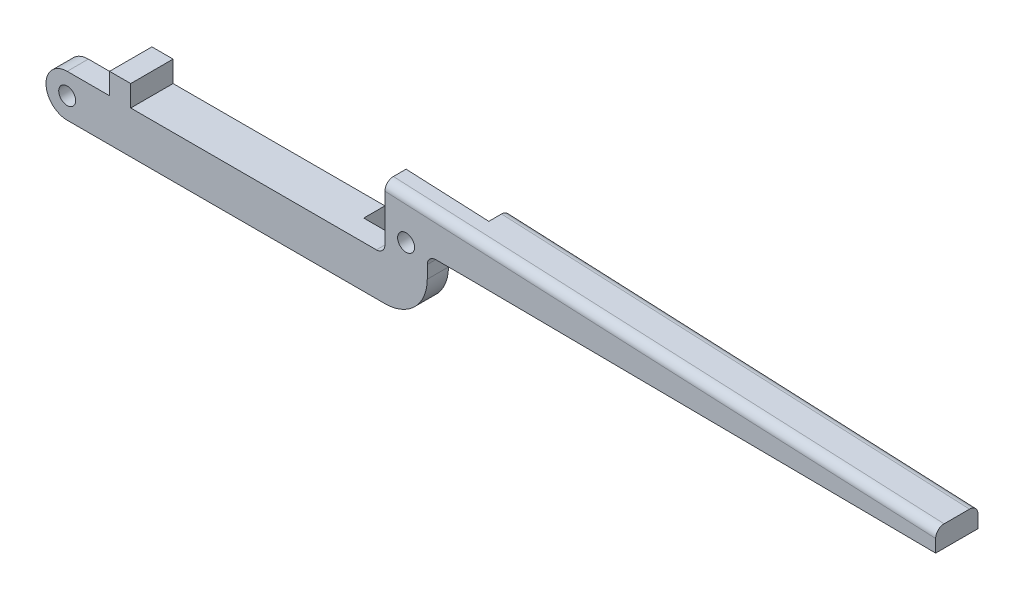
from build123d import *

# Parameters (mm, degrees)
BOSS_EXTRUDE1_DEPTH = 2.5
SKETCH2_W           = 2.5
SKETCH2_H           = 6.25
SKETCH2_H_2         = 2.5
CUT_EXTRUDE1_DEPTH  = 1.25
SKETCH3_R           = 0.5
CUT_EXTRUDE2_DEPTH  = 2.25
SKETCH4_W           = 2.5
SKETCH4_H           = 2.5
SKETCH4_R           = 0.5
SKETCH4_H_2         = 6.134615385
BOSS_EXTRUDE2_DEPTH = 1.25
BOSS_EXTRUDE3_DEPTH = 1.25
SKETCH6_W           = 2.5
SKETCH6_H           = 6.25
SKETCH6_H_2         = 2.5
CUT_EXTRUDE3_DEPTH  = 1.25
CUT_EXTRUDE4_DEPTH  = 1.25
CUT_EXTRUDE5_DEPTH  = 1.25
CUT_EXTRUDE6_DEPTH  = 1.25
CUT_EXTRUDE7_DEPTH  = 1.25
CUT_EXTRUDE8_DEPTH  = 1.25
BOSS_EXTRUDE4_DEPTH = 1.25
CUT_EXTRUDE9_DEPTH  = 1.25
FILLET2_R           = 0.5
FILLET3_R           = 0.5
FILLET4_R           = 0.5
CUT_EXTRUDE10_DEPTH = 1.25
SKETCH16_W          = 2.5
SKETCH16_H          = 2.5
BOSS_EXTRUDE5_DEPTH = 1.25
SKETCH17_W          = 27.617920392
SKETCH17_H          = 2.5
BOSS_EXTRUDE6_DEPTH = 0.25
CUT_EXTRUDE11_DEPTH = 3.5
SKETCH19_W          = 1.25
SKETCH19_H          = 1.25
CUT_EXTRUDE12_DEPTH = 3.5


with BuildPart() as part:
    # Sketch1 → Boss-Extrude1 (new body)
    with BuildSketch(Plane.XY):
        Polygon((0, -1.25), (0, -3.75), (20, -3.75), (22.5, -3.75), (22.5, 0), (52.5, 0), (52.5, 1), (20, 2.5), (20, 0), (20, -1.25), align=None)
    extrude(amount=BOSS_EXTRUDE1_DEPTH)

    # Sketch2 → Cut-Extrude1 (cut)
    with BuildSketch(Plane.XY.offset(2.5)):
        with Locations((21.25, -0.625)):
            Rectangle(SKETCH2_W, SKETCH2_H)
        with Locations((1.25, -2.5)):
            Rectangle(SKETCH2_W, SKETCH2_H_2)
    extrude(amount=-CUT_EXTRUDE1_DEPTH, mode=Mode.SUBTRACT)

    # Sketch3 → Cut-Extrude2 (cut, through all)
    with BuildSketch(Plane.XY.offset(1.25)):
        with Locations((1.25, -2.5)):
            Circle(SKETCH3_R)
        with Locations((21.25, 0)):
            Circle(SKETCH3_R)
    extrude(amount=-CUT_EXTRUDE2_DEPTH, mode=Mode.SUBTRACT)

    # Sketch4 → Boss-Extrude2 (add)
    with BuildSketch(Plane.XY.offset(1.25)):
        with Locations((1.25, -2.5)):
            Rectangle(SKETCH4_W, SKETCH4_H)
        with Locations((1.25, -2.5)):
            Circle(SKETCH4_R, mode=Mode.SUBTRACT)
        with Locations((21.25, -0.682692308)):
            Rectangle(SKETCH4_W, SKETCH4_H_2)
        with Locations((21.25, 0)):
            Circle(SKETCH4_R, mode=Mode.SUBTRACT)
    extrude(amount=BOSS_EXTRUDE2_DEPTH)

    # Sketch5 → Boss-Extrude3 (add)
    with BuildSketch(Plane.XY.offset(1.25)):
        Polygon((20, 2.384615385), (20, 2.5), (22.5, 2.384615385), align=None)
    extrude(amount=BOSS_EXTRUDE3_DEPTH)

    # Sketch6 → Cut-Extrude3 (cut)
    with BuildSketch(Plane(origin=(0, 0, 0), x_dir=(-1, 0, 0), z_dir=(0, 0, -1))):
        with Locations((-21.25, -0.625)):
            Rectangle(SKETCH6_W, SKETCH6_H)
        with Locations((-1.25, -2.5)):
            Rectangle(SKETCH6_W, SKETCH6_H_2)
    extrude(amount=-CUT_EXTRUDE3_DEPTH, mode=Mode.SUBTRACT)

    # Sketch7 → Cut-Extrude4 (cut)
    with BuildSketch(Plane(origin=(0, 0, 0), x_dir=(-1, 0, 0), z_dir=(0, 0, -1))):
        with BuildLine():
            Line((-2.5, -3.75), (-2.5, -1.25))
            ThreePointArc((-2.5, -1.25), (-3.75, -2.5), (-2.5, -3.75))
        make_face()
    extrude(amount=-CUT_EXTRUDE4_DEPTH, mode=Mode.SUBTRACT)

    # Sketch9 → Cut-Extrude5 (cut)
    with BuildSketch(Plane(origin=(0, 0, 1.25), x_dir=(-1, 0, 0), z_dir=(0, 0, -1))):
        with BuildLine():
            Line((0, -1.25), (-1.25, -1.25))
            ThreePointArc((-1.25, -1.25), (-0.366116524, -1.616116524), (0, -2.5))
            Line((0, -2.5), (0, -1.25))
        make_face()
        with BuildLine():
            Line((0, -3.75), (0, -2.5))
            ThreePointArc((0, -2.5), (-0.366116524, -3.383883476), (-1.25, -3.75))
            Line((-1.25, -3.75), (0, -3.75))
        make_face()
    extrude(amount=-CUT_EXTRUDE5_DEPTH, mode=Mode.SUBTRACT)

    # Sketch10 → Cut-Extrude6 (cut)
    with BuildSketch(Plane(origin=(0, 0, 0), x_dir=(-1, 0, 0), z_dir=(0, 0, -1))):
        with BuildLine():
            Line((-22.5, 2.384615385), (-24.882079608, 2.274673249))
            ThreePointArc((-24.882079608, 2.274673249), (-24.146848631, 0.660005249), (-22.5, 0))
            Line((-22.5, 0), (-22.5, 2.384615385))
        make_face()
        with BuildLine():
            Line((-20, -3.75), (-20, -1.25))
            Line((-20, -1.25), (-17.5, -1.25))
            ThreePointArc((-17.5, -1.25), (-18.232233047, -3.017766953), (-20, -3.75))
        make_face()
    extrude(amount=-CUT_EXTRUDE6_DEPTH, mode=Mode.SUBTRACT)

    # Sketch11 → Cut-Extrude7 (cut)
    with BuildSketch(Plane(origin=(0, 0, 1.25), x_dir=(-1, 0, 0), z_dir=(0, 0, -1))):
        with BuildLine():
            Line((-22.5, -1.25), (-22.5, -3.75))
            Line((-22.5, -3.75), (-20, -3.75))
            ThreePointArc((-20, -3.75), (-21.767766953, -3.017766953), (-22.5, -1.25))
        make_face()
    extrude(amount=-CUT_EXTRUDE7_DEPTH, mode=Mode.SUBTRACT)

    # Sketch12 → Cut-Extrude8 (cut)
    with BuildSketch(Plane(origin=(0, 0, 0), x_dir=(-1, 0, 0), z_dir=(0, 0, -1))):
        with BuildLine():
            Line((-24.882079608, 2.274673249), (-24.882079608, 0))
            Line((-24.882079608, 0), (-22.5, 0))
            ThreePointArc((-22.5, 0), (-24.146848631, 0.660005249), (-24.882079608, 2.274673249))
        make_face()
    extrude(amount=-CUT_EXTRUDE8_DEPTH, mode=Mode.SUBTRACT)

    # Sketch13 → Boss-Extrude4 (add)
    with BuildSketch(Plane(origin=(0, 0, 1.25), x_dir=(-1, 0, 0), z_dir=(0, 0, -1))):
        with BuildLine():
            Line((-2.5, -1.25), (-2, -1.25))
            ThreePointArc((-2, -1.25), (-2.5, -2.5), (-2, -3.75))
            Line((-2, -3.75), (-2.5, -3.75))
            ThreePointArc((-2.5, -3.75), (-3.75, -2.5), (-2.5, -1.25))
        make_face()
    extrude(amount=BOSS_EXTRUDE4_DEPTH)

    # Sketch14 → Cut-Extrude9 (cut)
    with BuildSketch(Plane(origin=(0, 0, 0), x_dir=(-1, 0, 0), z_dir=(0, 0, -1))):
        with BuildLine():
            Line((-17.5, -1.25), (-17.5, -3.75))
            Line((-17.5, -3.75), (-20, -3.75))
            ThreePointArc((-20, -3.75), (-18.232233047, -3.017766953), (-17.5, -1.25))
        make_face()
    extrude(amount=-CUT_EXTRUDE9_DEPTH, mode=Mode.SUBTRACT)

    # Fillet2
    fillet2_edges = [part.edges().sort_by_distance(p)[0] for p in [
        (38.691039804, 1.637336624, 0),
        (36.25, 1.75, 2.5),
    ]]
    fillet(fillet2_edges, radius=FILLET2_R)

    # Fillet3
    fillet3_edges = [part.edges().sort_by_distance(p)[0] for p in [
        (22.5, 0, 1.875),
    ]]
    fillet(fillet3_edges, radius=FILLET3_R)

    # Fillet4
    fillet4_edges = [part.edges().sort_by_distance(p)[0] for p in [
        (20, -1.25, 1.875),
    ]]
    fillet(fillet4_edges, radius=FILLET4_R)

    # Sketch15 → Cut-Extrude10 (cut)
    with BuildSketch(Plane(origin=(0, 0, 0), x_dir=(-1, 0, 0), z_dir=(0, 0, -1))):
        with BuildLine():
            Line((-2.5, -1.25), (-2.5, -2.500000004))
            ThreePointArc((-2.5, -2.500000004), (-2.370364003, -1.826854401), (-2, -1.25))
            Line((-2, -1.25), (-2.5, -1.25))
        make_face()
        with BuildLine():
            Line((-2.5, -3.75), (-2, -3.75))
            ThreePointArc((-2, -3.75), (-2.370364002, -3.173145603), (-2.5, -2.500000004))
            Line((-2.5, -2.500000004), (-2.5, -3.75))
        make_face()
    extrude(amount=-CUT_EXTRUDE10_DEPTH, mode=Mode.SUBTRACT)

    # Sketch16 → Boss-Extrude5 (add)
    with BuildSketch(Plane(origin=(0, -1.25, 0), x_dir=(1, 0, 0), z_dir=(0, 1, 0))):
        with Locations((3.75, -1.25)):
            Rectangle(SKETCH16_W, SKETCH16_H)
    extrude(amount=BOSS_EXTRUDE5_DEPTH)

    # Sketch17 → Boss-Extrude6 (add)
    with BuildSketch(Plane.XZ):
        with Locations((38.691039804, 1.25)):
            Rectangle(SKETCH17_W, SKETCH17_H)
    extrude(amount=BOSS_EXTRUDE6_DEPTH)

    # Sketch18 → Cut-Extrude11 (cut, through all)
    with BuildSketch(Plane(origin=(0, 0, 0), x_dir=(-1, 0, 0), z_dir=(0, 0, -1))):
        Polygon((-24.882079608, 0), (-52.5, -0.25), (-24.882079608, -0.25), align=None)
    extrude(amount=-CUT_EXTRUDE11_DEPTH, mode=Mode.SUBTRACT)

    # Sketch19 → Cut-Extrude12 (cut, through all)
    with BuildSketch(Plane(origin=(0, 0, 0), x_dir=(-1, 0, 0), z_dir=(0, 0, -1))):
        with Locations((-3.125, -0.625)):
            Rectangle(SKETCH19_W, SKETCH19_H)
    extrude(amount=-CUT_EXTRUDE12_DEPTH, mode=Mode.SUBTRACT)


solid = part.part
